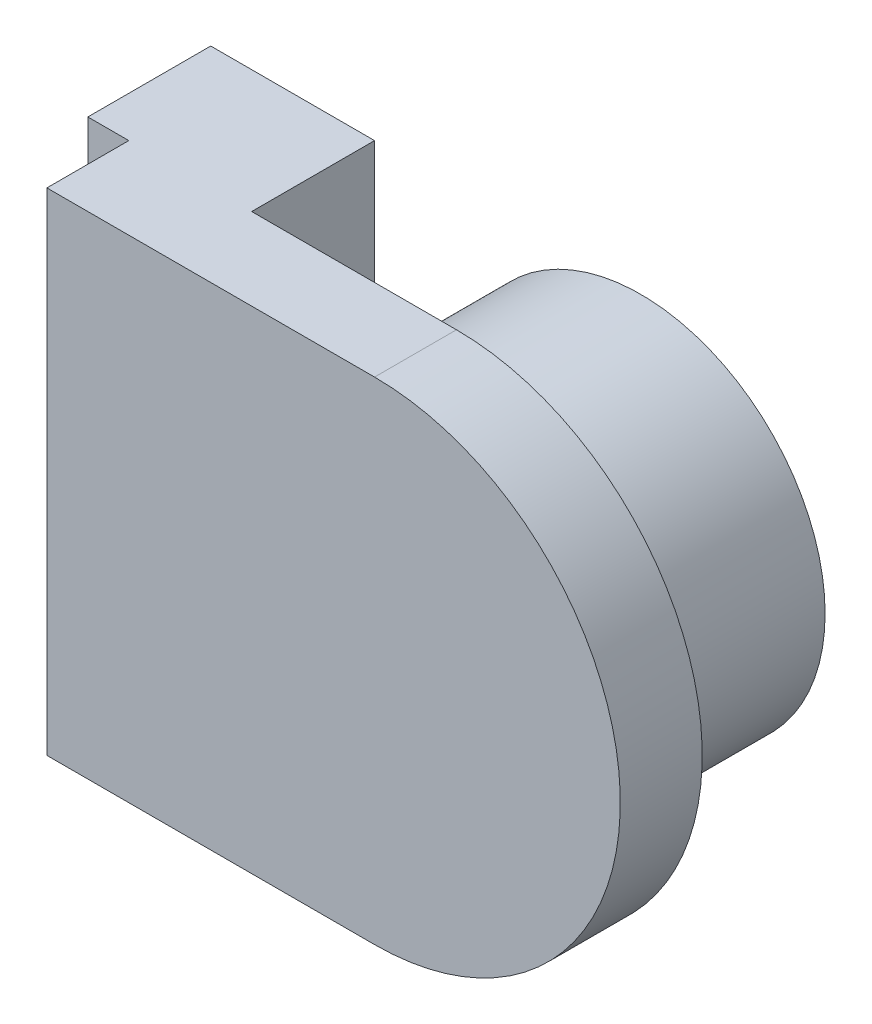
from build123d import *

# Parameters (mm, degrees)
BOSS_EXTRUDE1_DEPTH = 2
SKETCH1_3_R         = 4.5
BOSS_EXTRUDE2_DEPTH = 4.5
SKETCH1_4_R         = 0.5
BOSS_EXTRUDE3_DEPTH = 5
SKETCH3_W           = 4
SKETCH3_H           = 12
BOSS_EXTRUDE4_DEPTH = 3


with BuildPart() as part:
    # Sketch1 → Boss-Extrude1 (new body)
    with BuildSketch(Plane.XY):
        with BuildLine():
            Line((-8, 0), (0, 0))
            ThreePointArc((0, 0), (6, 6), (0, 12))
            Line((0, 12), (-8, 12))
            Line((-8, 12), (-8, 0))
        make_face()
    extrude(amount=BOSS_EXTRUDE1_DEPTH)



with BuildPart() as body_2:
    # Sketch1_3 → Boss-Extrude2 (new body)
    with BuildSketch(Plane.XY):
        with Locations((0, 6)):
            Circle(SKETCH1_3_R)
    extrude(amount=-BOSS_EXTRUDE2_DEPTH)


with BuildPart() as part_1:
    add(part.part)

    add(body_2.part)  # Boss-Extrude3 merges body 2
    # Sketch1_4 → Boss-Extrude3 (add)
    with BuildSketch(Plane.XY):
        with Locations((0, 6)):
            Circle(SKETCH1_4_R)
    extrude(amount=-BOSS_EXTRUDE3_DEPTH)

    # Sketch3 → Boss-Extrude4 (add)
    with BuildSketch(Plane(origin=(0, 0, 0), x_dir=(-1, 0, 0), z_dir=(0, 0, -1))):
        with Locations((7, 6)):
            Rectangle(SKETCH3_W, SKETCH3_H)
    extrude(amount=BOSS_EXTRUDE4_DEPTH)


solid = part_1.part
